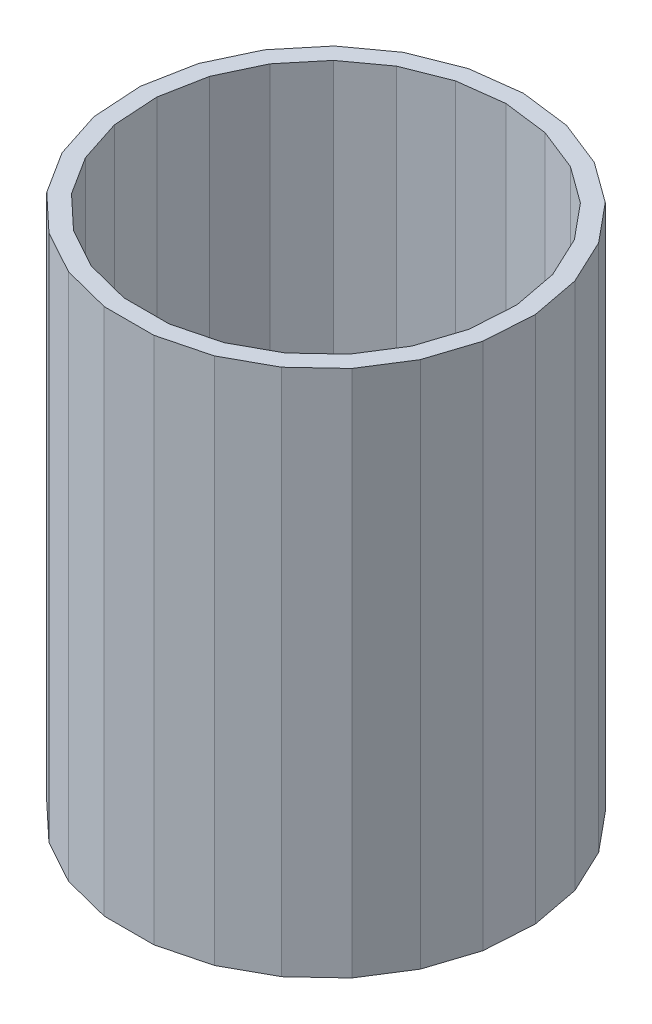
from build123d import *

# Parameters (mm, degrees)
BOSS_EXTRUDE1_DEPTH = 152.4


with BuildPart() as part:
    # Sketch2 → Boss-Extrude1 (new body)
    with BuildSketch(Plane(origin=(0, 0, 0), x_dir=(1, 0, 0), z_dir=(0, 1, 0))):
        Polygon((0, 57.15), (-14.212627051, 55.354527659), (-27.532222475, 50.080926765), (-39.121867104, 41.660557057), (-48.253340942, 30.622501333), (-54.352879906, 17.660321229), (-57.03722753, 3.588478191), (-56.137716379, -10.708842129), (-51.710866048, -24.333286513), (-44.034831825, -36.428781014), (-33.591927169, -46.235321229), (-21.038318186, -53.136726169), (-7.162794298, -56.69935518), (7.162794298, -56.69935518), (21.038318186, -53.136726169), (33.591927169, -46.235321229), (44.034831825, -36.428781014), (51.710866048, -24.333286513), (56.137716379, -10.708842129), (57.03722753, 3.588478191), (54.352879906, 17.660321229), (48.253340942, 30.622501333), (39.121867104, 41.660557057), (27.532222475, 50.080926765), (14.212627051, 55.354527659), align=None)
        Polygon((0, 52.07), (-12.949282425, 50.4341252), (-25.08491381, 45.62928883), (-35.644367806, 37.95739643), (-43.964155081, 27.900501215), (-49.521512803, 16.090514897), (-51.967251749, 3.269502352), (-51.147697145, -9.75694505), (-47.114344622, -22.170327712), (-40.120624551, -33.190667146), (-30.605978087, -42.125514897), (-19.168245458, -48.41346162), (-6.526101472, -51.659412497), (6.526101472, -51.659412497), (19.168245458, -48.41346162), (30.605978087, -42.125514897), (40.120624551, -33.190667146), (47.114344622, -22.170327712), (51.147697145, -9.75694505), (51.967251749, 3.269502352), (49.521512803, 16.090514897), (43.964155081, 27.900501215), (35.644367806, 37.95739643), (25.08491381, 45.62928883), (12.949282425, 50.4341252), align=None, mode=Mode.SUBTRACT)
    extrude(amount=BOSS_EXTRUDE1_DEPTH)


solid = part.part
